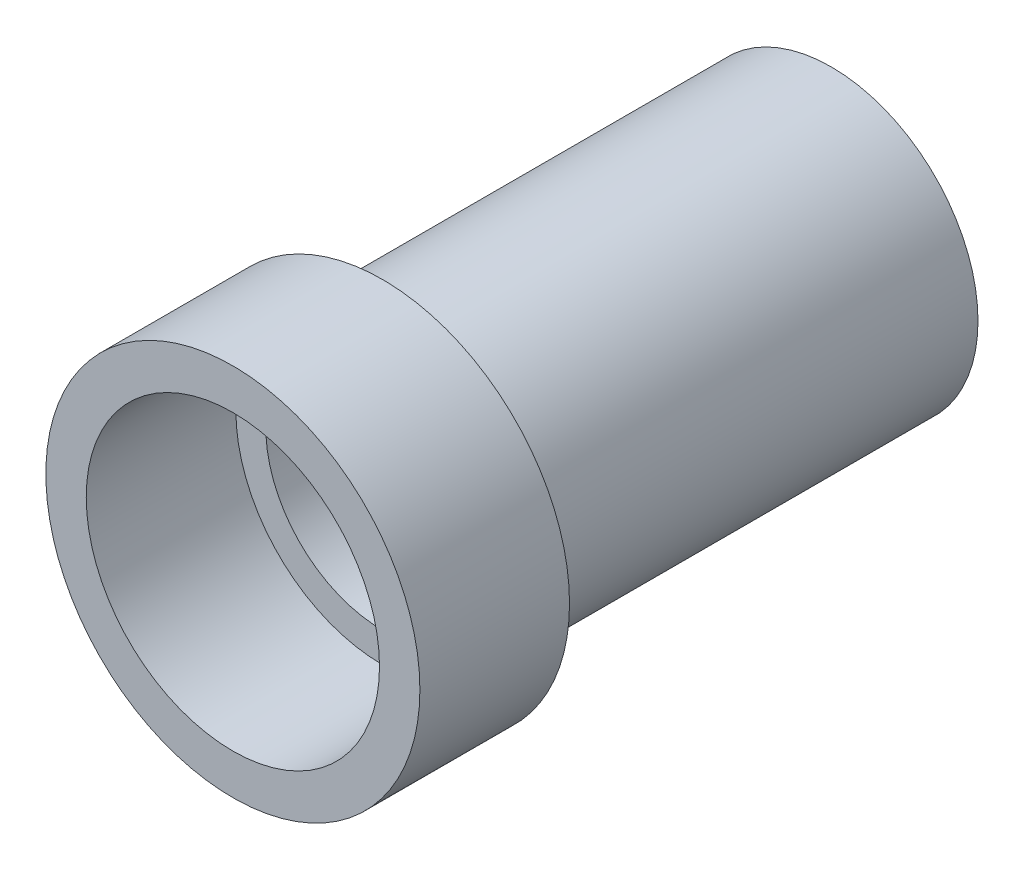
from build123d import *

# Parameters (mm, degrees)
SKETCH1_R           = 12.446
SKETCH1_R_2         = 9.906
EXTRUDE_THIN1_DEPTH = 38.1
SKETCH1_3_R         = 15.875
SKETCH1_3_R_2       = 12.446
EXTRUDE1_DEPTH      = 12.7


with BuildPart() as part:
    # Sketch1 → Extrude-Thin1 (new body)
    with BuildSketch(Plane.XY):
        with Locations((0, 142.24)):
            Circle(SKETCH1_R)
        with Locations((0, 142.24)):
            Circle(SKETCH1_R_2, mode=Mode.SUBTRACT)
    extrude(amount=-EXTRUDE_THIN1_DEPTH)


with BuildPart() as body_2:
    # Sketch1_3 → Extrude1 (new body)
    with BuildSketch(Plane.XY):
        with Locations((0, 142.24)):
            Circle(SKETCH1_3_R)
        with Locations((0, 142.24)):
            Circle(SKETCH1_3_R_2, mode=Mode.SUBTRACT)
    extrude(amount=EXTRUDE1_DEPTH)


solid = Compound([part.part, body_2.part])
